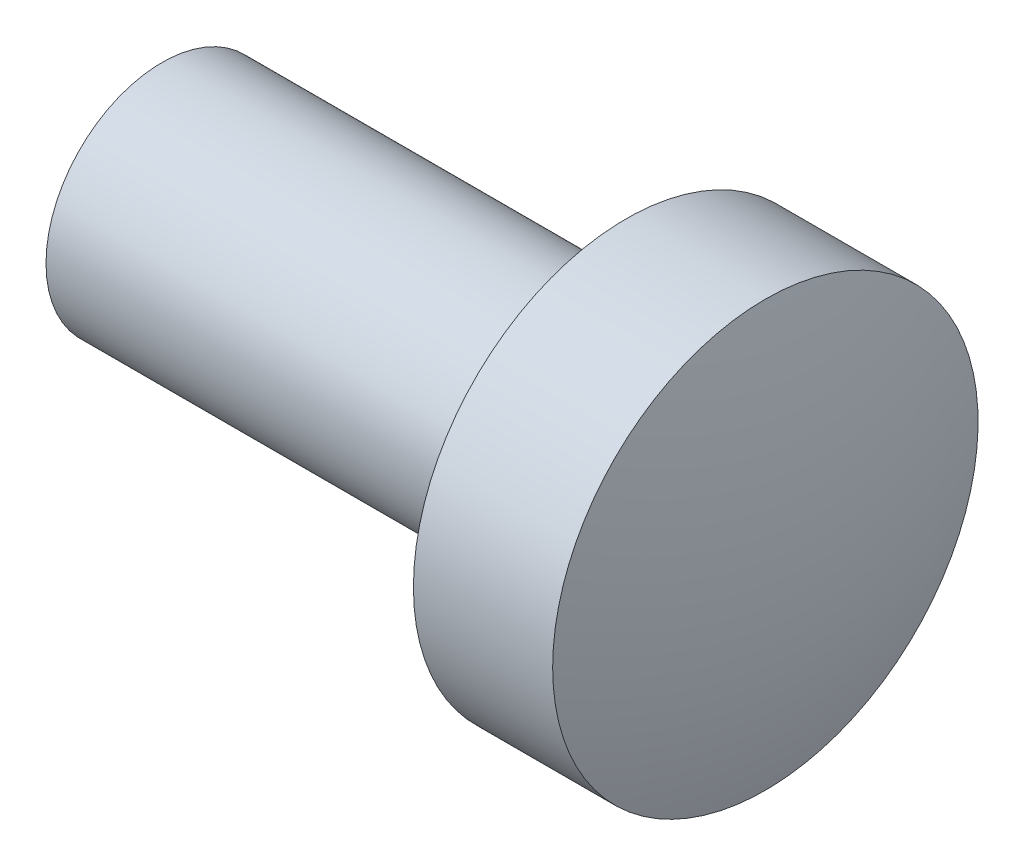
from build123d import *


with BuildPart() as part:
    # Esquisse1 → Révolution1 (revolve)
    with BuildSketch(Plane.XY):
        with BuildLine():
            Line((0, 1.5), (0, 2.75))
            Line((0, 2.75), (1.8, 2.75))
            ThreePointArc((1.8, 2.75), (2.099476597, 1.389469323), (2.2, 0))
            Line((2.2, 0), (-6, 0))
            Line((-6, 0), (-6, 1.5))
            Line((-6, 1.5), (0, 1.5))
        make_face()
    revolve(axis=Axis((-16.30139048, 0, 0), (1, 0, 0)))


solid = part.part
